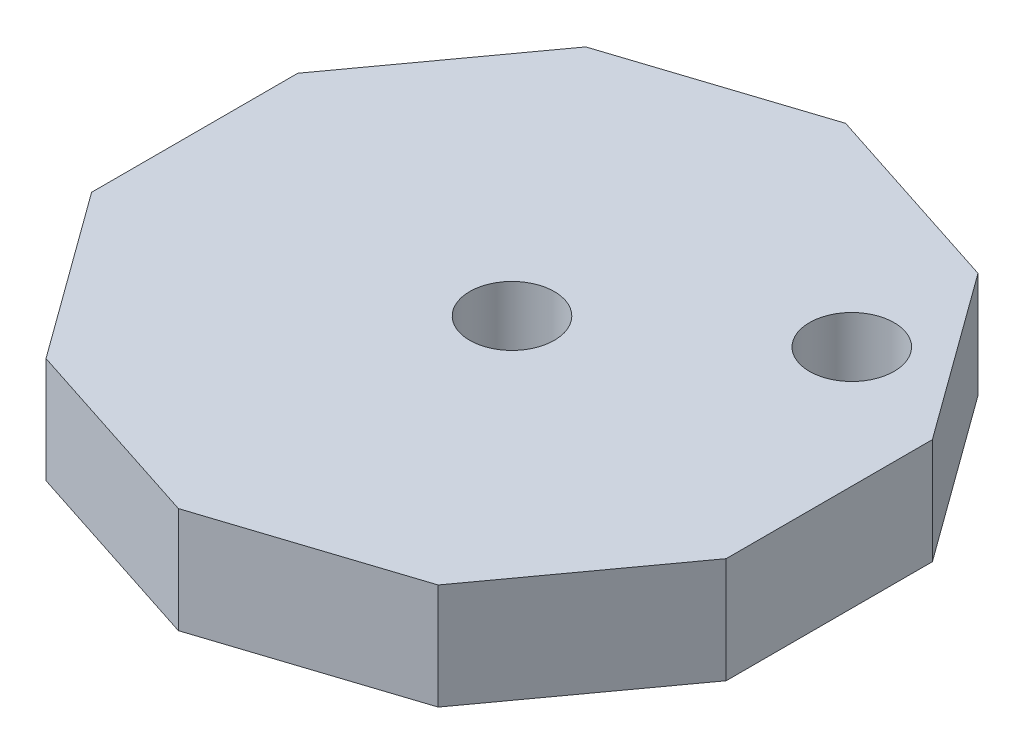
from build123d import *

# Parameters (mm, degrees)
BOSS_EXTRUDE1_DEPTH = 5
SKETCH2_R           = 2
CUT_EXTRUDE1_DEPTH  = 5


with BuildPart() as part:
    # Sketch1 → Boss-Extrude1 (new body)
    with BuildSketch(Plane(origin=(0, 0, 0), x_dir=(1, 0, 0), z_dir=(0, 1, 0))):
        Polygon((9.270509831, -12.759762125), (15, -4.873795443), (15, 4.873795443), (9.270509831, 12.759762125), (0, 15.771933364), (-9.270509831, 12.759762125), (-15, 4.873795443), (-15, -4.873795443), (-9.270509831, -12.759762125), (0, -15.771933364), align=None)
    extrude(amount=BOSS_EXTRUDE1_DEPTH)

    # Sketch2 → Cut-Extrude1 (cut)
    with BuildSketch(Plane(origin=(0, 5, 0), x_dir=(1, 0, 0), z_dir=(0, 1, 0))):
        Circle(SKETCH2_R)
        with Locations((9.303695435, 6.759530401)):
            Circle(SKETCH2_R)
    extrude(amount=-CUT_EXTRUDE1_DEPTH, mode=Mode.SUBTRACT)


solid = part.part
